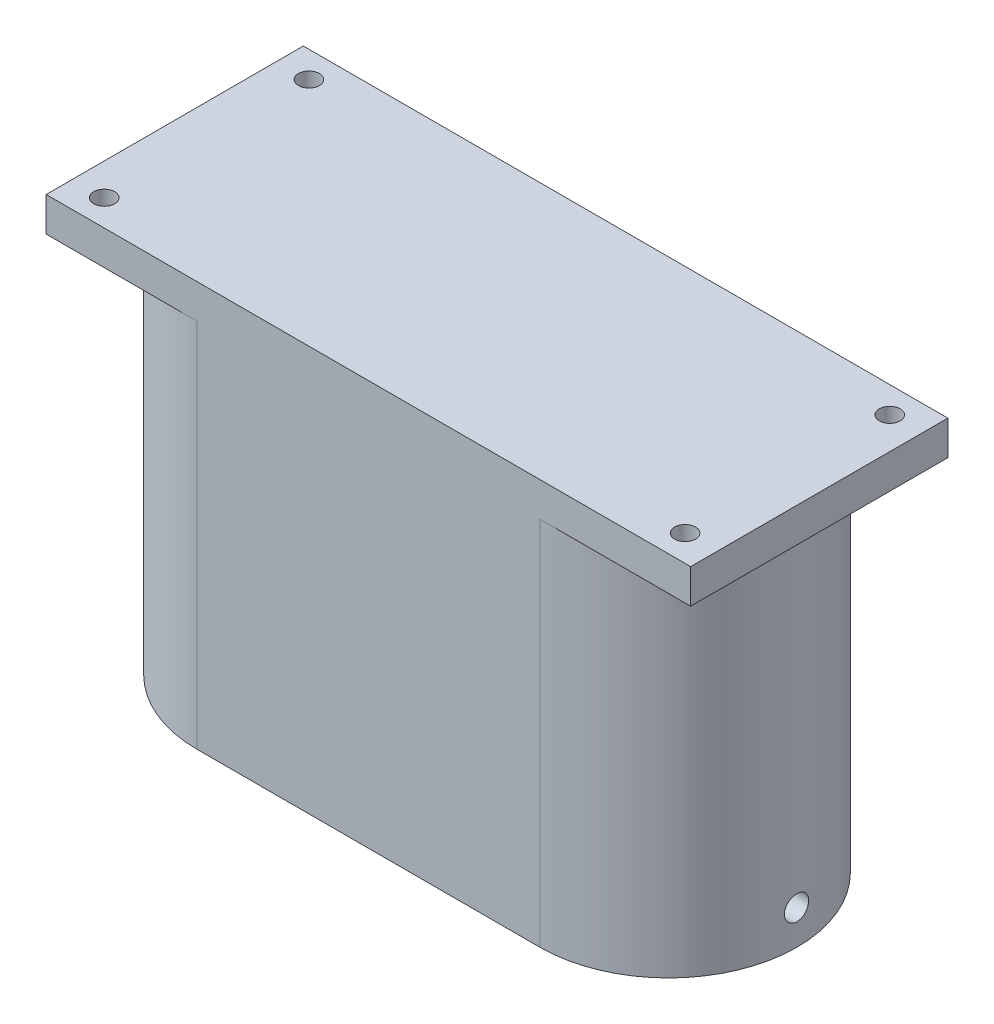
from build123d import *

# Parameters (mm, degrees)
BOSS_EXTRUDE1_DEPTH     = 60
SKETCH2_W               = 95.474406292
SKETCH2_H               = 38.1
SKETCH2_R               = 1.55
BOSS_EXTRUDE2_DEPTH     = 5.08
SKETCH4_R               = 1.8
CUT_EXTRUDE1_DEPTH      = 96.52
CUT_EXTRUDE1_DEPTH_BACK = 107.696


with BuildPart() as part:
    # Sketch1 → Boss-Extrude1 (new body)
    with BuildSketch(Plane(origin=(0, 0, 0), x_dir=(1, 0, 0), z_dir=(0, 1, 0))):
        with BuildLine():
            Line((-25.4, -19.05), (25.4, -19.05))
            ThreePointArc((25.4, -19.05), (44.45, 0), (25.4, 19.05))
            Line((25.4, 19.05), (-25.4, 19.05))
            ThreePointArc((-25.4, 19.05), (-44.45, 0), (-25.4, -19.05))
        make_face()
        with BuildLine():
            Line((-25.4, -13.97), (25.4, -13.97))
            ThreePointArc((25.4, -13.97), (39.37, 0), (25.4, 13.97))
            Line((25.4, 13.97), (-25.4, 13.97))
            ThreePointArc((-25.4, 13.97), (-39.37, 0), (-25.4, -13.97))
        make_face(mode=Mode.SUBTRACT)
    extrude(amount=BOSS_EXTRUDE1_DEPTH)

    # Sketch2 → Boss-Extrude2 (add)
    with BuildSketch(Plane(origin=(0, 60, 0), x_dir=(1, 0, 0), z_dir=(0, 1, 0))):
        Rectangle(SKETCH2_W, SKETCH2_H)
        with Locations((43.019742204, 15.162081353)):
            Circle(SKETCH2_R, mode=Mode.SUBTRACT)
        with Locations((43.019742204, -15.162081353)):
            Circle(SKETCH2_R, mode=Mode.SUBTRACT)
        with Locations((-43.019742204, -15.162081353)):
            Circle(SKETCH2_R, mode=Mode.SUBTRACT)
        with Locations((-43.019742204, 15.162081353)):
            Circle(SKETCH2_R, mode=Mode.SUBTRACT)
    extrude(amount=-BOSS_EXTRUDE2_DEPTH)

    # Sketch4 → Cut-Extrude1 (cut, two sides)
    with BuildSketch(Plane(origin=(0, 0, 0), x_dir=(0, 0, -1), z_dir=(1, 0, 0))) as cut_extrude1_sk:
        with Locations((0, 5.08)):
            Circle(SKETCH4_R)
    extrude(amount=CUT_EXTRUDE1_DEPTH, mode=Mode.SUBTRACT)
    extrude(cut_extrude1_sk.sketch, amount=-CUT_EXTRUDE1_DEPTH_BACK, mode=Mode.SUBTRACT)


solid = part.part
